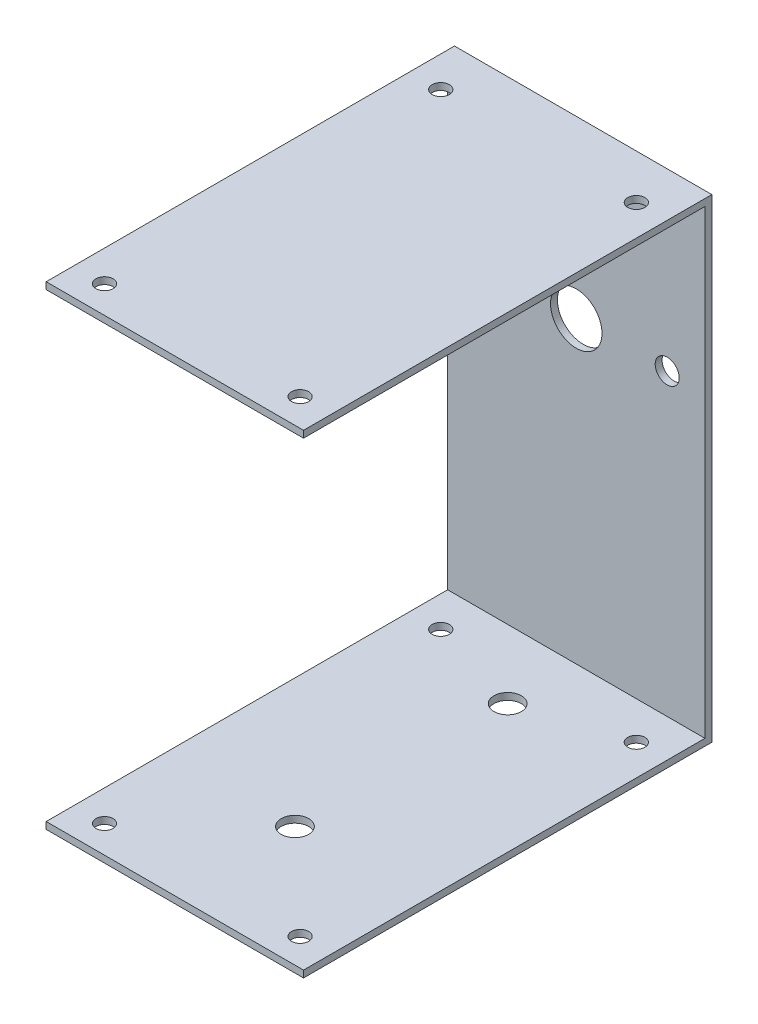
from build123d import *

# Parameters (mm, degrees)
ESBO_O1_W                = 75
ESBO_O1_H                = 117
RESSALTO_EXTRUS_O1_DEPTH = 2
ESBO_O2_W                = 75
ESBO_O2_H                = 2
RESSALTO_EXTRUS_O2_DEPTH = 136.25
ESBO_O3_W                = 75
ESBO_O3_H                = 119
RESSALTO_EXTRUS_O3_DEPTH = 2
ESBO_O4_R                = 2.5
CORTE_EXTRUS_O1_DEPTH    = 139.25
ESBO_O5_R                = 7.5
CORTE_EXTRUS_O2_DEPTH    = 10
CORTE_EXTRUS_O3_DEPTH    = 10
ESBO_O7_R                = 4
CORTE_EXTRUS_O4_DEPTH    = 10


with BuildPart() as part:
    # Esboço1 → Ressalto-extrusão1 (new body)
    with BuildSketch(Plane(origin=(0, 0, 0), x_dir=(1, 0, 0), z_dir=(0, 1, 0))):
        Rectangle(ESBO_O1_W, ESBO_O1_H)
    extrude(amount=RESSALTO_EXTRUS_O1_DEPTH)

    # Esboço2 → Ressalto-extrusão2 (add)
    with BuildSketch(Plane(origin=(0, 0, 0), x_dir=(1, 0, 0), z_dir=(0, 1, 0))):
        with Locations((0, 59.5)):
            Rectangle(ESBO_O2_W, ESBO_O2_H)
    extrude(amount=RESSALTO_EXTRUS_O2_DEPTH)

    # Esboço3 → Ressalto-extrusão3 (add)
    with BuildSketch(Plane(origin=(0, 136.25, 0), x_dir=(1, 0, 0), z_dir=(0, 1, 0))):
        with Locations((0, 1)):
            Rectangle(ESBO_O3_W, ESBO_O3_H)
    extrude(amount=RESSALTO_EXTRUS_O3_DEPTH)

    # Esboço4 → Corte-extrusão1 (cut, through all)
    with BuildSketch(Plane.XZ):
        with Locations((28.5, -47.5)):
            Circle(ESBO_O4_R)
        with Locations((-28.5, -47.5)):
            Circle(ESBO_O4_R)
        with Locations((28.5, 50.5)):
            Circle(ESBO_O4_R)
        with Locations((-28.5, 50.5)):
            Circle(ESBO_O4_R)
    extrude(amount=-CORTE_EXTRUS_O1_DEPTH, mode=Mode.SUBTRACT)

    # Esboço5 → Corte-extrusão2 (cut)
    with BuildSketch(Plane(origin=(0, 0, -60.5), x_dir=(-1, 0, 0), z_dir=(0, 0, -1))):
        with Locations((0, 89.2)):
            Circle(ESBO_O5_R)
    extrude(amount=-CORTE_EXTRUS_O2_DEPTH, mode=Mode.SUBTRACT)

    # Esboço6 → Corte-extrusão3 (cut)
    with BuildSketch(Plane.XY.offset(-58.5)):
        with BuildLine():
            ThreePointArc((26.5, 85.7), (30, 89.2), (26.5, 92.7))
            ThreePointArc((26.5, 92.7), (23, 89.2), (26.5, 85.7))
        make_face()
        with BuildLine():
            ThreePointArc((-26.5, 85.7), (-23, 89.2), (-26.5, 92.7))
            ThreePointArc((-26.5, 92.7), (-30, 89.2), (-26.5, 85.7))
        make_face()
    extrude(amount=-CORTE_EXTRUS_O3_DEPTH, mode=Mode.SUBTRACT)

    # Esboço7 → Corte-extrusão4 (cut)
    with BuildSketch(Plane.XZ):
        with Locations((0, -38.5)):
            Circle(ESBO_O7_R)
        with Locations((0, 23.5)):
            Circle(ESBO_O7_R)
    extrude(amount=-CORTE_EXTRUS_O4_DEPTH, mode=Mode.SUBTRACT)


solid = part.part
